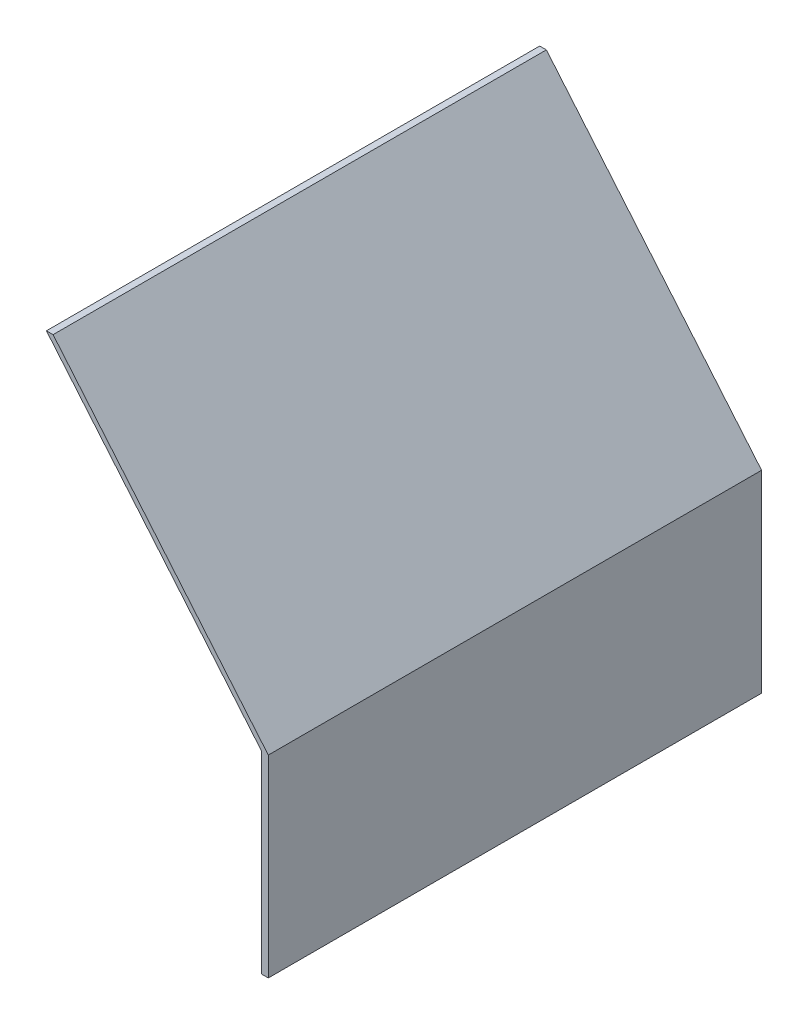
from build123d import *

# Parameters (mm, degrees)
BOSS_EXTRUDE1_DEPTH = 112.268


with BuildPart() as part:
    # Sketch1 → Boss-Extrude1 (new body)
    with BuildSketch(Plane.XY):
        Polygon((0, 0), (-1.51892, 0), (-1.51892, 43.942), (-50.499335858, 102.314586566), (-48.980415858, 102.314586566), (0, 43.942), align=None)
    extrude(amount=BOSS_EXTRUDE1_DEPTH)


solid = part.part
